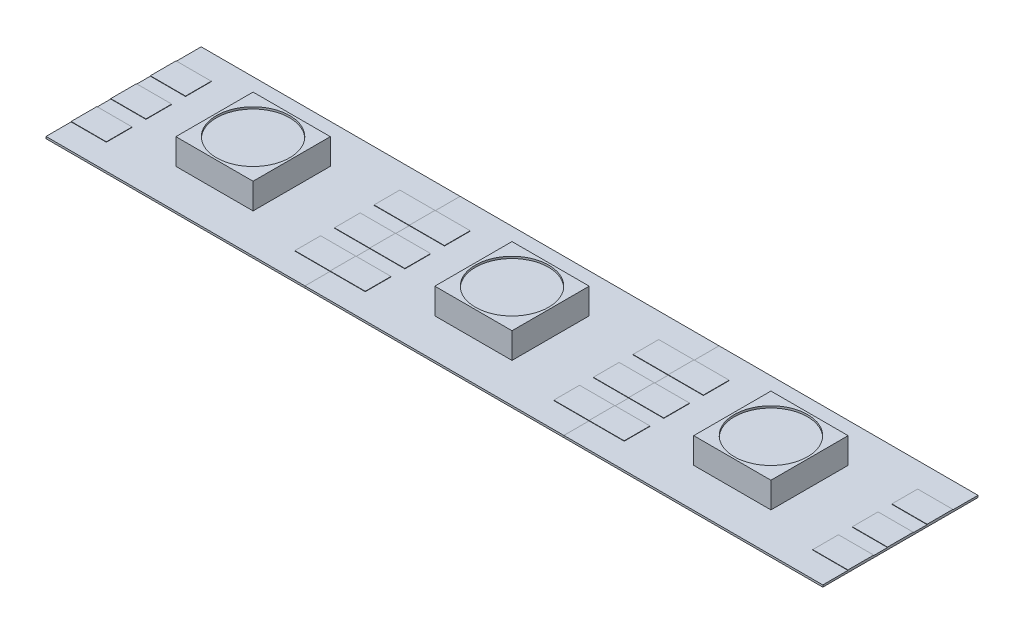
from build123d import *

# Parameters (mm, degrees)
SKETCH1_W           = 16.6116
SKETCH1_H           = 9.9568
BOSS_EXTRUDE1_DEPTH = 0.127
SKETCH3_W           = 4.953
SKETCH3_H           = 4.953
BOSS_EXTRUDE3_DEPTH = 1.651
SKETCH4_W           = 2.258810151
SKETCH4_H           = 1.651
BOSS_EXTRUDE4_DEPTH = 0.0254
SKETCH5_R           = 2.348345572
CUT_EXTRUDE1_DEPTH  = 0.127
LPATTERN1_COUNT     = 3
LPATTERN1_PITCH     = 16.6116


with BuildPart() as part:
    # Sketch1 → Boss-Extrude1 (new body)
    with BuildSketch(Plane(origin=(0, 0, 0), x_dir=(1, 0, 0), z_dir=(0, 1, 0))):
        Rectangle(SKETCH1_W, SKETCH1_H)
    extrude(amount=BOSS_EXTRUDE1_DEPTH)

    # Sketch3 → Boss-Extrude3 (add)
    with BuildSketch(Plane(origin=(0, 0.127, 0), x_dir=(1, 0, 0), z_dir=(0, 1, 0))):
        Rectangle(SKETCH3_W, SKETCH3_H)
    extrude(amount=BOSS_EXTRUDE3_DEPTH)

    # Sketch4 → Boss-Extrude4 (add)
    with BuildSketch(Plane(origin=(0, 0.127, 0), x_dir=(1, 0, 0), z_dir=(0, 1, 0))):
        with Locations((-7.176394925, 0)):
            Rectangle(SKETCH4_W, SKETCH4_H)
        with Locations((-7.176394925, 2.54)):
            Rectangle(SKETCH4_W, SKETCH4_H)
        with Locations((-7.176394925, -2.54)):
            Rectangle(SKETCH4_W, SKETCH4_H)
        with Locations((7.176394925, -2.54)):
            Rectangle(SKETCH4_W, SKETCH4_H)
        with Locations((7.176394925, 0)):
            Rectangle(SKETCH4_W, SKETCH4_H)
        with Locations((7.176394925, 2.54)):
            Rectangle(SKETCH4_W, SKETCH4_H)
    extrude(amount=BOSS_EXTRUDE4_DEPTH)

    # Sketch5 → Cut-Extrude1 (cut)
    with BuildSketch(Plane(origin=(0, 1.778, 0), x_dir=(1, 0, 0), z_dir=(0, 1, 0))):
        Circle(SKETCH5_R)
    extrude(amount=-CUT_EXTRUDE1_DEPTH, mode=Mode.SUBTRACT)


with BuildPart() as lpattern1_1:
    # LPattern1: pattern copy
    add(part.part.moved(Location(Vector(1, 0, 0) * (1 * LPATTERN1_PITCH))))


with BuildPart() as lpattern1_2:
    # LPattern1: pattern copy
    add(part.part.moved(Location(Vector(1, 0, 0) * (2 * LPATTERN1_PITCH))))


solid = Compound([part.part, lpattern1_1.part, lpattern1_2.part])
